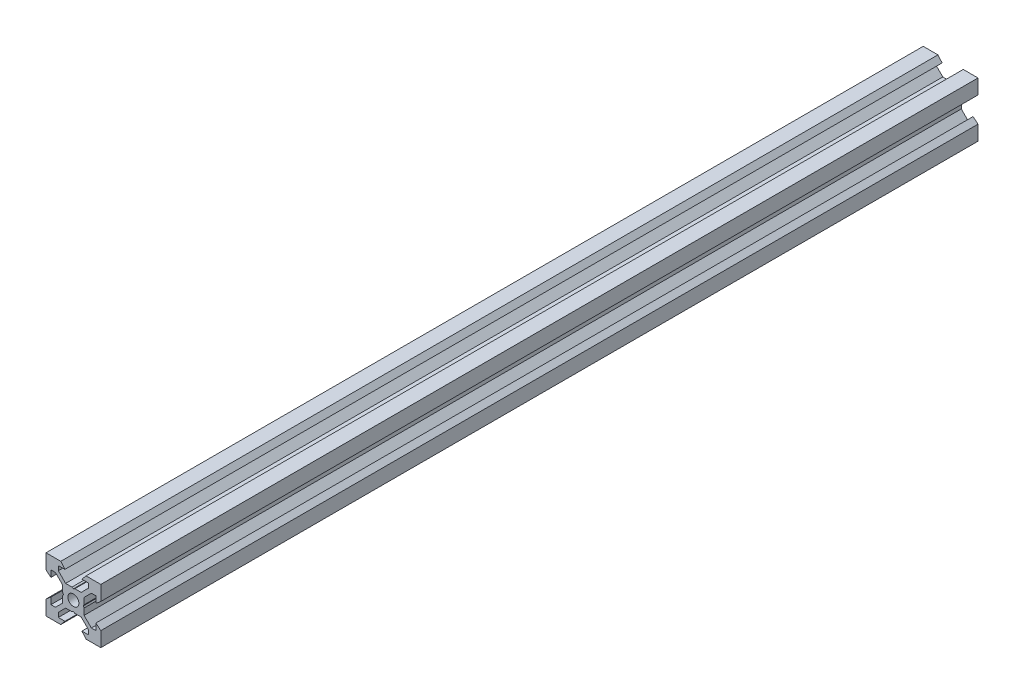
from build123d import *

# Parameters (mm, degrees)
SKETCH1_R           = 2
BOSS_EXTRUDE1_DEPTH = 160.09


with BuildPart() as part:
    # Sketch1 → Boss-Extrude1 (new body, symmetric)
    with BuildSketch(Plane.XY):
        Polygon((10, 10), (10, 4.610379336), (8.2, 3.1), (8.2, 5.5), (6.560660172, 5.5), (3.9, 2.839339828), (3.9, 0.519615242), (3.6, 0), (3.9, -0.519615242), (3.9, -2.839339828), (6.560660172, -5.5), (8.2, -5.5), (8.2, -3.1), (10, -4.610379336), (10, -10), (4.610379336, -10), (3.1, -8.2), (5.5, -8.2), (5.5, -6.560660172), (2.839339828, -3.9), (0.519615242, -3.9), (0, -3.6), (-0.519615242, -3.9), (-2.839339828, -3.9), (-5.5, -6.560660172), (-5.5, -8.2), (-3.1, -8.2), (-4.610379336, -10), (-10, -10), (-10, -4.610379336), (-8.2, -3.1), (-8.2, -5.5), (-6.560660172, -5.5), (-3.9, -2.839339828), (-3.9, -0.519615242), (-3.6, 0), (-3.9, 0.519615242), (-3.9, 2.839339828), (-6.560660172, 5.5), (-8.2, 5.5), (-8.2, 3.1), (-10, 4.610379336), (-10, 10), (-4.610379336, 10), (-3.1, 8.2), (-5.5, 8.2), (-5.5, 6.560660172), (-2.839339828, 3.9), (-0.519615242, 3.9), (0, 3.6), (0.519615242, 3.9), (2.839339828, 3.9), (5.5, 6.560660172), (5.5, 8.2), (3.1, 8.2), (4.610379336, 10), align=None)
        Circle(SKETCH1_R, mode=Mode.SUBTRACT)
    extrude(amount=BOSS_EXTRUDE1_DEPTH, both=True)


solid = part.part
